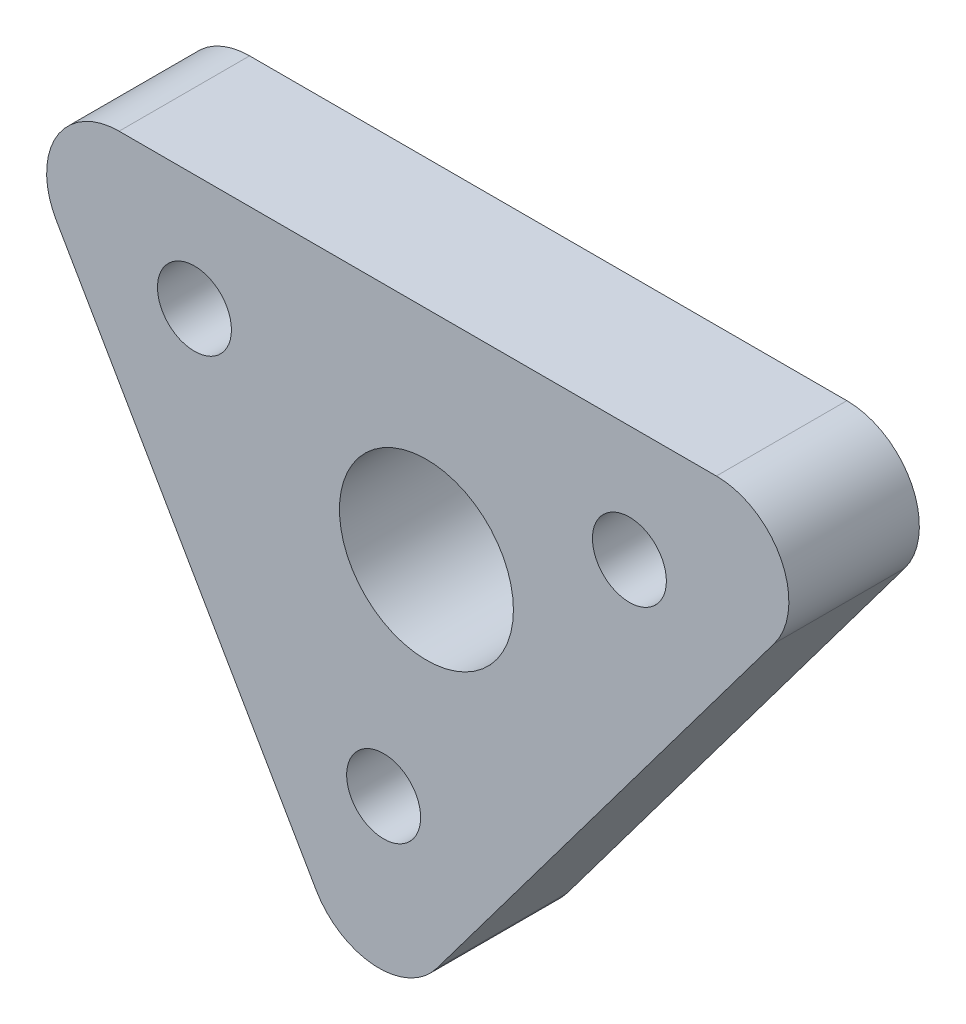
from build123d import *

# Parameters (mm, degrees)
SKETCH_1_R      = 2.55
SKETCH_1_R_2    = 6
EXTRUDE_1_DEPTH = 9
FILLET_1_R      = 5


with BuildPart() as part:
    # 草图1 → 凸台-拉伸1 (new body)
    with BuildSketch(Plane.XY):
        Polygon((-54.053450796, 27.320514858), (5.802955665, 27.320514858), (-28.018037849, -17.774143161), align=None)
        with Locations((-40.197044335, 19.320514858)):
            Circle(SKETCH_1_R, mode=Mode.SUBTRACT)
        with Locations((-27.148108815, -3.280904448)):
            Circle(SKETCH_1_R, mode=Mode.SUBTRACT)
        with Locations((-10.197044335, 19.320514858)):
            Circle(SKETCH_1_R, mode=Mode.SUBTRACT)
        with Locations((-24.197044335, 12.320514858)):
            Circle(SKETCH_1_R_2, mode=Mode.SUBTRACT)
    extrude(amount=EXTRUDE_1_DEPTH)

    # 圆角1
    fillet_1_edges = [part.edges().sort_by_distance(p)[0] for p in [
        (-54.053450796, 27.320514858, 4.5),
        (5.802955665, 27.320514858, 4.5),
        (-28.018037849, -17.774143161, 4.5),
    ]]
    fillet(fillet_1_edges, radius=FILLET_1_R)


solid = part.part
